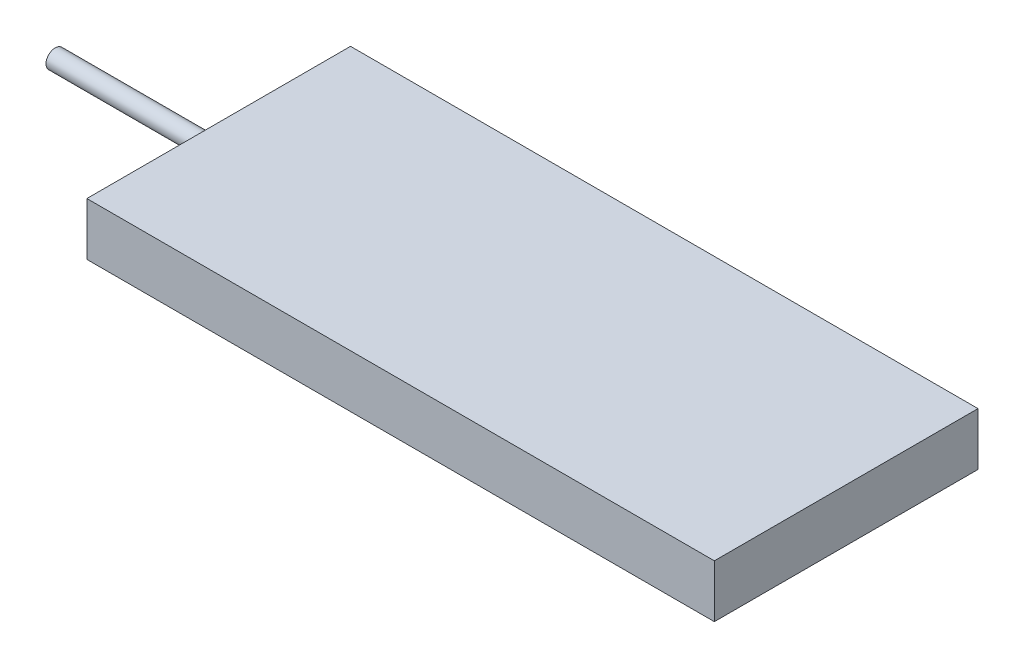
from build123d import *

# Parameters (mm, degrees)
SKETCH_1_W      = 238
SKETCH_1_H      = 100
EXTRUDE_2_DEPTH = 20
SKETCH_2_R      = 3.5
EXTRUDE_3_DEPTH = 62


with BuildPart() as part:
    # 草图1 → 凸台-拉伸2 (new body)
    with BuildSketch(Plane(origin=(0, 0, 0), x_dir=(1, 0, 0), z_dir=(0, 1, 0))):
        with Locations((119, 50)):
            Rectangle(SKETCH_1_W, SKETCH_1_H)
    extrude(amount=EXTRUDE_2_DEPTH)

    # 草图2 → 凸台-拉伸3 (add)
    with BuildSketch(Plane.ZY):
        with Locations((-50, 10)):
            Circle(SKETCH_2_R)
    extrude(amount=EXTRUDE_3_DEPTH)


solid = part.part
